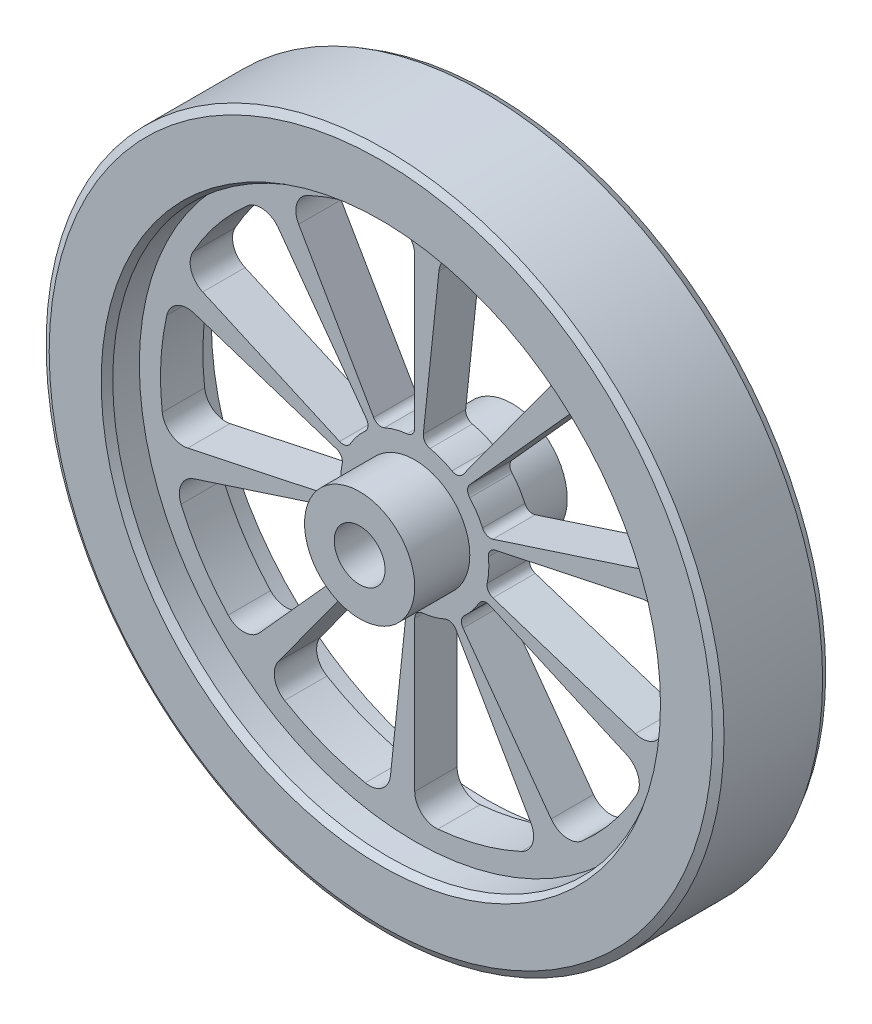
from build123d import *

# Parameters (mm, degrees)
SKETCH1_R             = 80
SKETCH1_R_2           = 6
BOSS_EXTRUDE1_DEPTH   = 13
SKETCH2_R             = 65
CUT_EXTRUDE1_DEPTH    = 8
SKETCH3_R             = 13
SKETCH3_R_2           = 6
BOSS_EXTRUDE3_DEPTH   = 18
CHAMFER1_SIZE         = 1
CHAMFER1_SIZE2        = 1.732050808
CHAMFER1_PART_2_SIZE  = 1
CHAMFER1_PART_2_SIZE2 = 1.732050808
CHAMFER1_PART_3_SIZE  = 1
CHAMFER1_PART_3_SIZE2 = 1.732050808
CHAMFER1_PART_4_SIZE  = 1
CHAMFER1_PART_4_SIZE2 = 1.732050808
CUT_EXTRUDE2_DEPTH    = 24
CIRPATTERN1_COUNT     = 10


with BuildPart() as part:
    # Sketch1 → Boss-Extrude1 (new body, symmetric)
    with BuildSketch(Plane.XY):
        Circle(SKETCH1_R)
        Circle(SKETCH1_R_2, mode=Mode.SUBTRACT)
    extrude(amount=BOSS_EXTRUDE1_DEPTH, both=True)

    # Sketch2 → Cut-Extrude1 (cut)
    with BuildSketch(Plane.XY.offset(13)):
        Circle(SKETCH2_R)
    cut_extrude1 = extrude(amount=-CUT_EXTRUDE1_DEPTH, mode=Mode.SUBTRACT)

    # Mirror1: Cut-Extrude1 across plane
    add(cut_extrude1.mirror(Plane.XY), mode=Mode.SUBTRACT)

    # Sketch3 → Boss-Extrude3 (add, symmetric)
    with BuildSketch(Plane.XY):
        Circle(SKETCH3_R)
        Circle(SKETCH3_R_2, mode=Mode.SUBTRACT)
    extrude(amount=BOSS_EXTRUDE3_DEPTH, both=True)

    # Chamfer1
    chamfer1_edges = [part.edges().sort_by_distance(p)[0] for p in [
        (-65, 0, 13),
    ]]
    chamfer1_side = [part.faces().sort_by_distance(p)[0] for p in [
        (-77.7372583, 0, 13),
    ]]
    chamfer(chamfer1_edges, length=CHAMFER1_SIZE, length2=CHAMFER1_SIZE2, reference=chamfer1_side[0])

    # Chamfer1 part 2
    chamfer1_part_2_edges = [part.edges().sort_by_distance(p)[0] for p in [
        (-65, 0, -13),
    ]]
    chamfer1_part_2_side = [part.faces().sort_by_distance(p)[0] for p in [
        (-65, 0, -9),
    ]]
    chamfer(chamfer1_part_2_edges, length=CHAMFER1_PART_2_SIZE, length2=CHAMFER1_PART_2_SIZE2, reference=chamfer1_part_2_side[0])

    # Chamfer1 part 3
    chamfer1_part_3_edges = [part.edges().sort_by_distance(p)[0] for p in [
        (-80, 0, -13),
    ]]
    chamfer1_part_3_side = [part.faces().sort_by_distance(p)[0] for p in [
        (-77.7372583, 0, -13),
    ]]
    chamfer(chamfer1_part_3_edges, length=CHAMFER1_PART_3_SIZE, length2=CHAMFER1_PART_3_SIZE2, reference=chamfer1_part_3_side[0])

    # Chamfer1 part 4
    chamfer1_part_4_edges = [part.edges().sort_by_distance(p)[0] for p in [
        (-80, 0, 13),
    ]]
    chamfer1_part_4_side = [part.faces().sort_by_distance(p)[0] for p in [
        (-80, 0, 0),
    ]]
    chamfer(chamfer1_part_4_edges, length=CHAMFER1_PART_4_SIZE, length2=CHAMFER1_PART_4_SIZE2, reference=chamfer1_part_4_side[0])

    # Sketch4 → Cut-Extrude2 (cut, through all)
    with BuildSketch(Plane.XY.offset(5)):
        with BuildLine():
            Line((0, 54.772255751), (0, 19.397164741))
            ThreePointArc((0, 19.397164741), (-0.515032591, 18.057436487), (-1.794871795, 17.407711947))
            ThreePointArc((-1.794871795, 17.407711947), (-4.529333289, 16.90370196), (-7.149451403, 15.972956666))
            ThreePointArc((-7.149451403, 15.972956666), (-8.582686936, 15.895715021), (-9.698582371, 16.798437427))
            Line((-9.698582371, 16.798437427), (-27.386127875, 47.434164903))
            ThreePointArc((-27.386127875, 47.434164903), (-27.821744262, 51.446675992), (-25.152000934, 54.473634439))
            ThreePointArc((-25.152000934, 54.473634439), (-15.529142706, 57.955549577), (-5.454545455, 59.751551728))
            ThreePointArc((-5.454545455, 59.751551728), (-1.629000688, 58.46500048), (0, 54.772255751))
        make_face()
    cut_extrude2 = extrude(amount=-CUT_EXTRUDE2_DEPTH, mode=Mode.SUBTRACT)

    # CirPattern1: Cut-Extrude2 ×10 about axis
    cirpattern1_axis = Axis((0, 0, 0), (0, 0, 1))
    for i in range(1, CIRPATTERN1_COUNT):
        add(cut_extrude2.rotate(cirpattern1_axis, i * 360 / CIRPATTERN1_COUNT), mode=Mode.SUBTRACT)


solid = part.part
